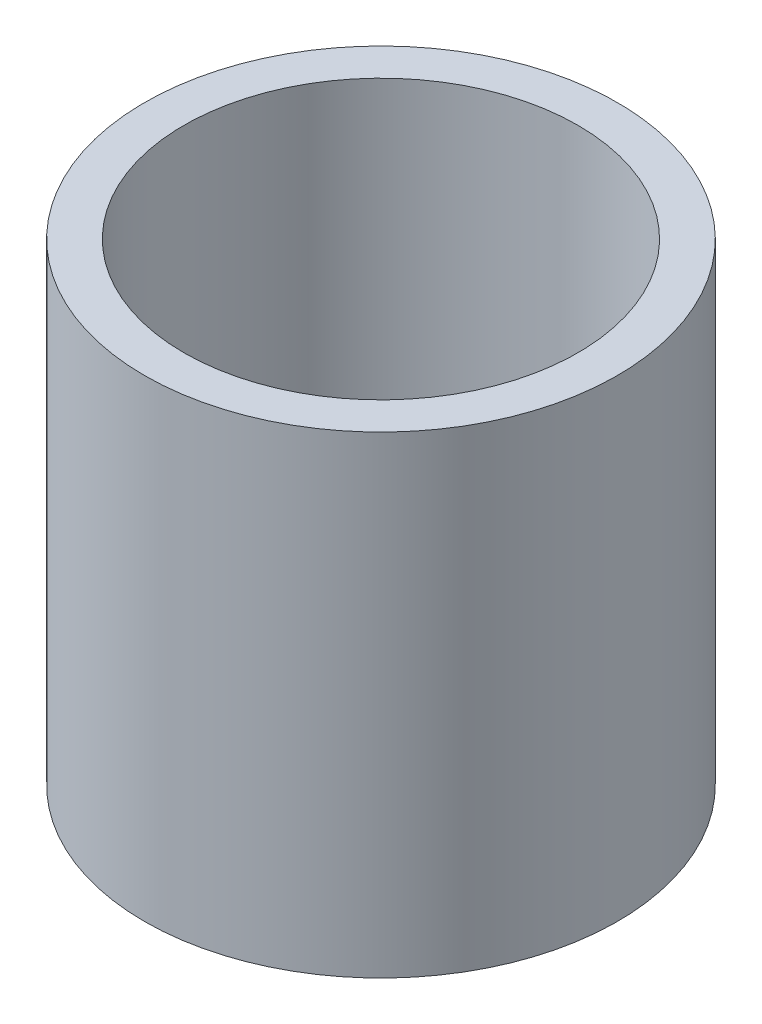
from build123d import *

# Parameters (mm, degrees)
SKETCH1_R           = 9
SKETCH1_R_2         = 7.5
BOSS_EXTRUDE1_DEPTH = 18


with BuildPart() as part:
    # Sketch1 → Boss-Extrude1 (new body)
    with BuildSketch(Plane(origin=(0, 0, 0), x_dir=(1, 0, 0), z_dir=(0, 1, 0))):
        Circle(SKETCH1_R)
        Circle(SKETCH1_R_2, mode=Mode.SUBTRACT)
    extrude(amount=BOSS_EXTRUDE1_DEPTH)


solid = part.part
